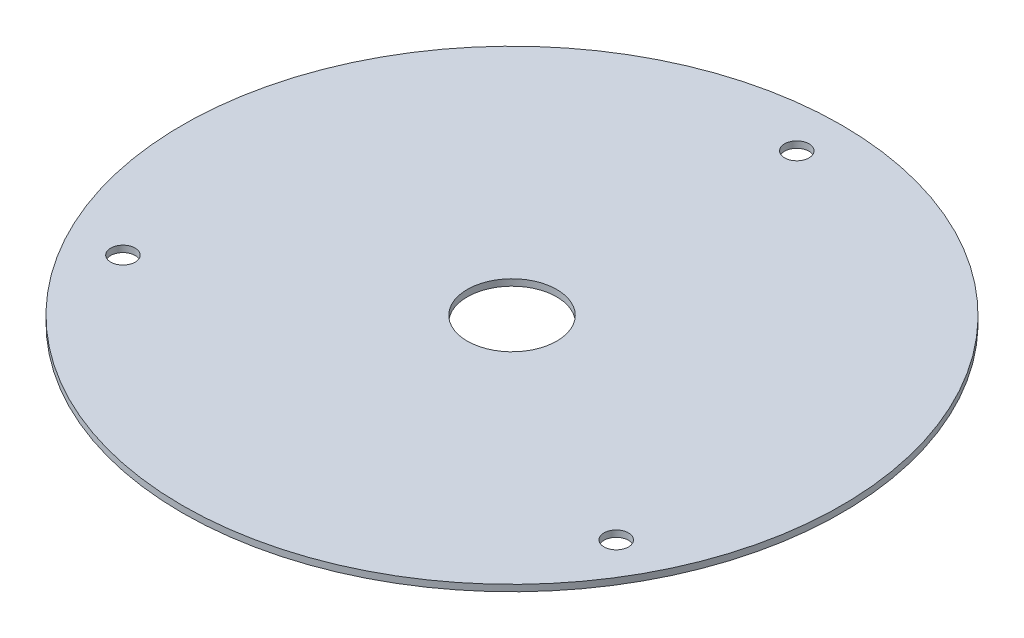
from build123d import *

# Parameters (mm, degrees)
SKETCH1_R           = 81
SKETCH1_R_2         = 11
SKETCH1_R_3         = 3
BOSS_EXTRUDE1_DEPTH = 1.5875


with BuildPart() as part:
    # Sketch1 → Boss-Extrude1 (new body)
    with BuildSketch(Plane(origin=(0, 0, 0), x_dir=(1, 0, 0), z_dir=(0, 1, 0))):
        Circle(SKETCH1_R)
        Circle(SKETCH1_R_2, mode=Mode.SUBTRACT)
        with Locations((0, 70)):
            Circle(SKETCH1_R_3, mode=Mode.SUBTRACT)
        with Locations((60.621778265, -35)):
            Circle(SKETCH1_R_3, mode=Mode.SUBTRACT)
        with Locations((-60.621778265, -35)):
            Circle(SKETCH1_R_3, mode=Mode.SUBTRACT)
    extrude(amount=BOSS_EXTRUDE1_DEPTH)


solid = part.part
